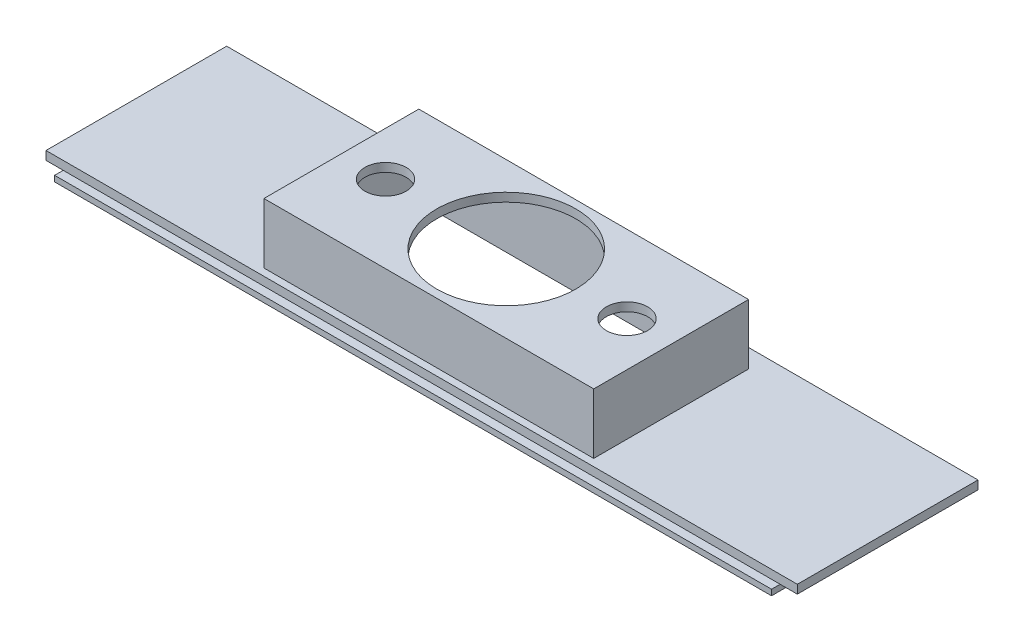
from build123d import *

# Parameters (mm, degrees)
SKETCH1_W           = 254
SKETCH1_H           = 59
BOSS_EXTRUDE1_DEPTH = 3
SKETCH2_W           = 115
SKETCH2_H           = 54
BOSS_EXTRUDE2_DEPTH = 21
SKETCH3_W           = 111
SKETCH3_H           = 50
CUT_EXTRUDE3_DEPTH  = 21
SKETCH4_R           = 7.2
SKETCH4_R_2         = 24.25
CUT_EXTRUDE4_DEPTH  = 3
SKETCH5_W           = 250
SKETCH5_H           = 59
SKETCH5_W_2         = 111
SKETCH5_H_2         = 50
BOSS_EXTRUDE3_DEPTH = 2
SKETCH6_W           = 59
SKETCH6_H           = 3
BOSS_EXTRUDE4_DEPTH = 4
SKETCH7_W           = 258
SKETCH7_H           = 3
BOSS_EXTRUDE5_DEPTH = 4
SKETCH8_W           = 63
SKETCH8_H           = 3
BOSS_EXTRUDE6_DEPTH = 4
SKETCH9_W           = 250
SKETCH9_H           = 2
BOSS_EXTRUDE7_DEPTH = 1


with BuildPart() as part:
    # Sketch1 → Boss-Extrude1 (new body)
    with BuildSketch(Plane(origin=(0, 0, 0), x_dir=(1, 0, 0), z_dir=(0, 1, 0))):
        Rectangle(SKETCH1_W, SKETCH1_H)
    extrude(amount=BOSS_EXTRUDE1_DEPTH)

    # Sketch2 → Boss-Extrude2 (add)
    with BuildSketch(Plane(origin=(0, 3, 0), x_dir=(1, 0, 0), z_dir=(0, 1, 0))):
        Rectangle(SKETCH2_W, SKETCH2_H)
    extrude(amount=BOSS_EXTRUDE2_DEPTH)

    # Sketch3 → Cut-Extrude3 (cut)
    with BuildSketch(Plane.XZ):
        Rectangle(SKETCH3_W, SKETCH3_H)
    extrude(amount=-CUT_EXTRUDE3_DEPTH, mode=Mode.SUBTRACT)

    # Sketch4 → Cut-Extrude4 (cut)
    with BuildSketch(Plane(origin=(0, 24, 0), x_dir=(1, 0, 0), z_dir=(0, 1, 0))):
        with Locations((-42.1, 0)):
            Circle(SKETCH4_R)
        Circle(SKETCH4_R_2)
        with Locations((42.1, 0)):
            Circle(SKETCH4_R)
    extrude(amount=-CUT_EXTRUDE4_DEPTH, mode=Mode.SUBTRACT)

    # Sketch5 → Boss-Extrude3 (add)
    with BuildSketch(Plane.XZ):
        with Locations((0, 2)):
            Rectangle(SKETCH5_W, SKETCH5_H)
        Rectangle(SKETCH5_W_2, SKETCH5_H_2, mode=Mode.SUBTRACT)
    extrude(amount=BOSS_EXTRUDE3_DEPTH)

    # Sketch6 → Boss-Extrude4 (add)
    with BuildSketch(Plane.ZY.offset(127)):
        with Locations((0, 1.5)):
            Rectangle(SKETCH6_W, SKETCH6_H)
    extrude(amount=BOSS_EXTRUDE4_DEPTH)

    # Sketch7 → Boss-Extrude5 (add)
    with BuildSketch(Plane(origin=(0, 0, -29.5), x_dir=(-1, 0, 0), z_dir=(0, 0, -1))):
        with Locations((2, 1.5)):
            Rectangle(SKETCH7_W, SKETCH7_H)
    extrude(amount=BOSS_EXTRUDE5_DEPTH)

    # Sketch8 → Boss-Extrude6 (add)
    with BuildSketch(Plane(origin=(127, 0, 0), x_dir=(0, 0, -1), z_dir=(1, 0, 0))):
        with Locations((2, 1.5)):
            Rectangle(SKETCH8_W, SKETCH8_H)
    extrude(amount=BOSS_EXTRUDE6_DEPTH)

    # Sketch9 → Boss-Extrude7 (add)
    with BuildSketch(Plane.XY.offset(31.5)):
        with Locations((0, -1)):
            Rectangle(SKETCH9_W, SKETCH9_H)
    extrude(amount=BOSS_EXTRUDE7_DEPTH)


solid = part.part
